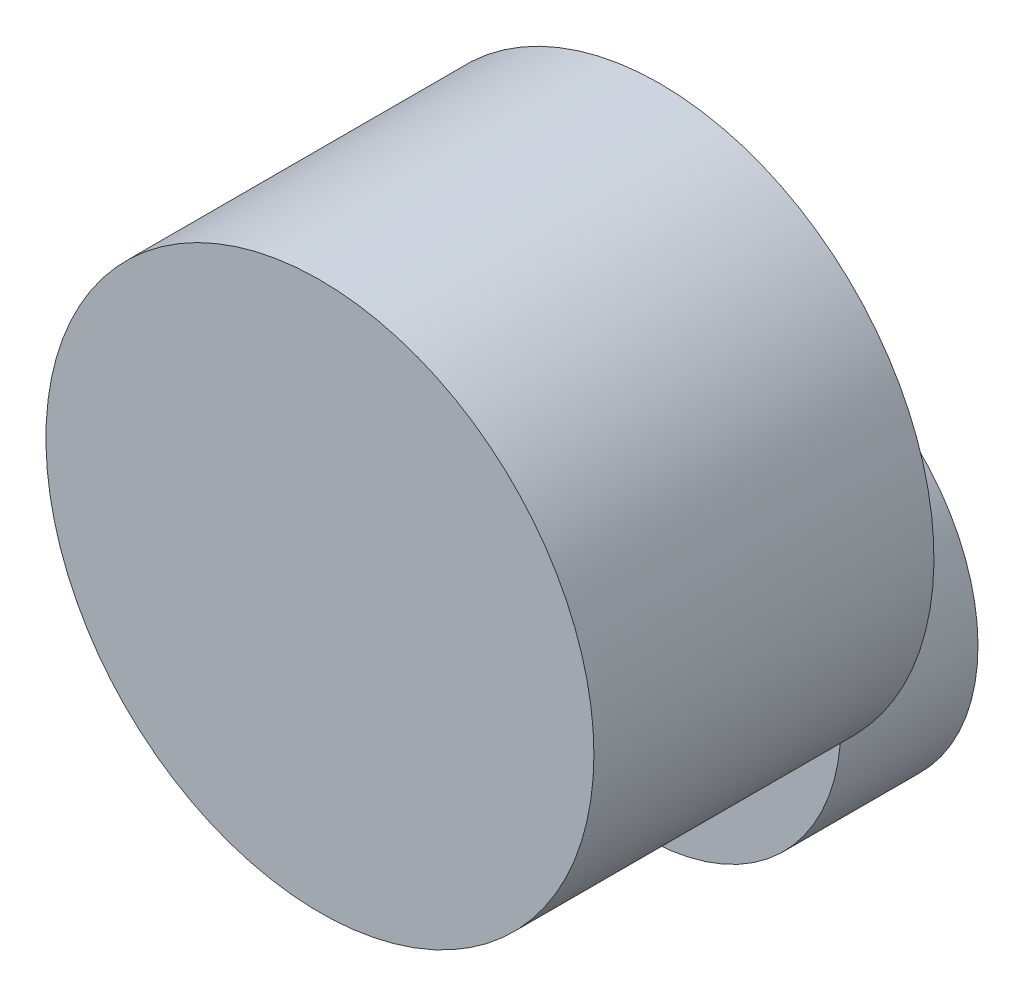
from build123d import *

# Parameters (mm, degrees)
SKETCH1_R           = 56
EXTRUDE1_DEPTH      = 69.5
EXTRUDE2_DEPTH      = 25
EXTRUDE2_DEPTH_BACK = 3
SKETCH2_R           = 40
SKETCH3_R           = 2.5
CUT_EXTRUDE1_DEPTH  = 10
SKETCH4_R           = 6.35
EXTRUDE3_DEPTH      = 12.7


with BuildPart() as part:
    # Sketch1 → Extrude1 (new body)
    with BuildSketch(Plane.XY):
        Circle(SKETCH1_R)
    extrude(amount=EXTRUDE1_DEPTH)

    # Sketch2 → Extrude2 (add, two sides: drawn at the far end of the back side and taken through both)
    with BuildSketch(Plane(origin=(0, 0, 0), x_dir=(-1, 0, 0), z_dir=(0, 0, -1)).offset(-EXTRUDE2_DEPTH_BACK)):
        with Locations((0, -36)):
            Circle(SKETCH2_R)
    extrude(amount=EXTRUDE2_DEPTH + EXTRUDE2_DEPTH_BACK)

    # Sketch3 → Cut-Extrude1 (cut)
    with BuildSketch(Plane(origin=(0, 0, 0), x_dir=(-1, 0, 0), z_dir=(0, 0, -1))):
        with Locations((-49, 0)):
            Circle(SKETCH3_R)
        with Locations((0, 49)):
            Circle(SKETCH3_R)
        with Locations((49, 0)):
            Circle(SKETCH3_R)
    extrude(amount=-CUT_EXTRUDE1_DEPTH, mode=Mode.SUBTRACT)

    # Sketch4 → Extrude3 (add)
    with BuildSketch(Plane(origin=(0, 0, -25), x_dir=(-1, 0, 0), z_dir=(0, 0, -1))):
        with Locations((0, -36)):
            Circle(SKETCH4_R)
    extrude(amount=EXTRUDE3_DEPTH)


solid = part.part
